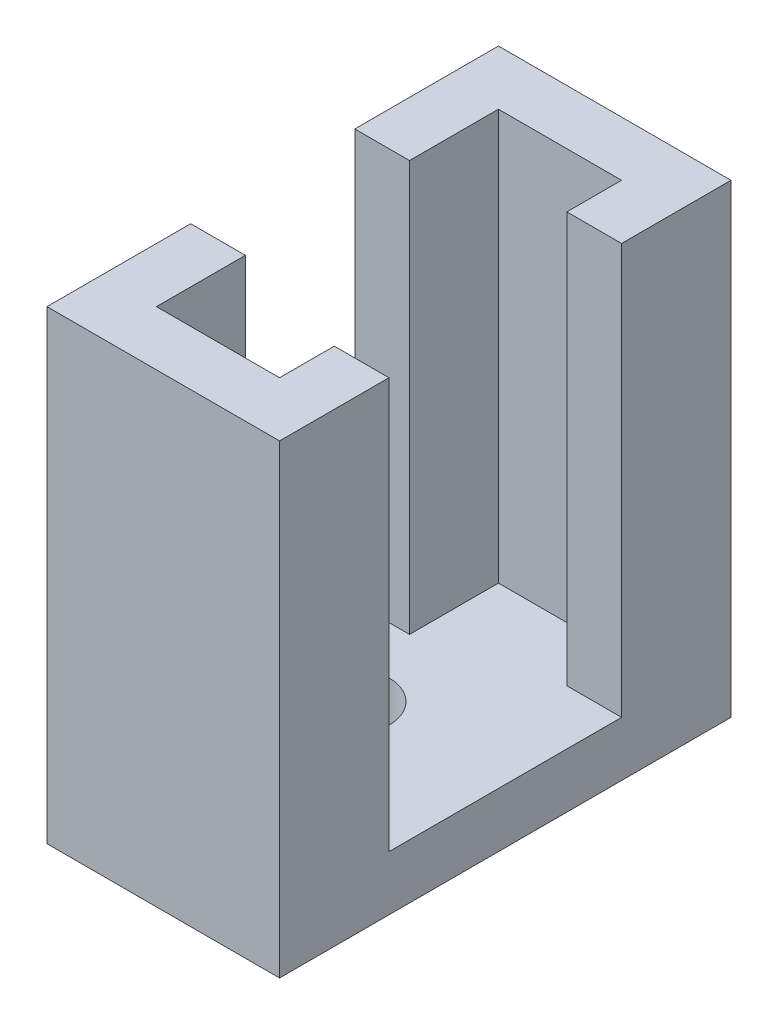
from build123d import *

# Parameters (mm, degrees)
BOSS_EXTRUDE1_DEPTH = 15
SKETCH3_W           = 8.5
SKETCH3_H           = 16.5
SKETCH3_R           = 1
SKETCH3_R_2         = 1.5
BOSS_EXTRUDE2_DEPTH = 2
SKETCH4_W           = 6
SKETCH4_H           = 20
CUT_EXTRUDE1_DEPTH  = 2


with BuildPart() as part:
    # Sketch2 → Boss-Extrude1 (new body)
    with BuildSketch(Plane(origin=(0, 0, 0), x_dir=(1, 0, 0), z_dir=(0, 1, 0))):
        Polygon((0, 0), (-4.5, 0), (-4.5, -12.5), (0, -12.5), (0, -10.5), (2, -10.5), (2, -14.5), (-6.5, -14.5), (-6.5, 2), (2, 2), (2, -2), (0, -2), align=None)
    extrude(amount=BOSS_EXTRUDE1_DEPTH)

    # Sketch3 → Boss-Extrude2 (add)
    with BuildSketch(Plane.XZ):
        with Locations((-2.25, 6.25)):
            Rectangle(SKETCH3_W, SKETCH3_H)
        with Locations((-3.5, 11.5)):
            Circle(SKETCH3_R, mode=Mode.SUBTRACT)
        with Locations((-3.5, 6.5)):
            Circle(SKETCH3_R_2, mode=Mode.SUBTRACT)
    extrude(amount=BOSS_EXTRUDE2_DEPTH)

    # Sketch4 → Cut-Extrude1 (cut)
    with BuildSketch(Plane(origin=(-4.5, 0, 0), x_dir=(0, 0, -1), z_dir=(1, 0, 0))):
        with Locations((-6.25, 10)):
            Rectangle(SKETCH4_W, SKETCH4_H)
    extrude(amount=-CUT_EXTRUDE1_DEPTH, mode=Mode.SUBTRACT)


solid = part.part
